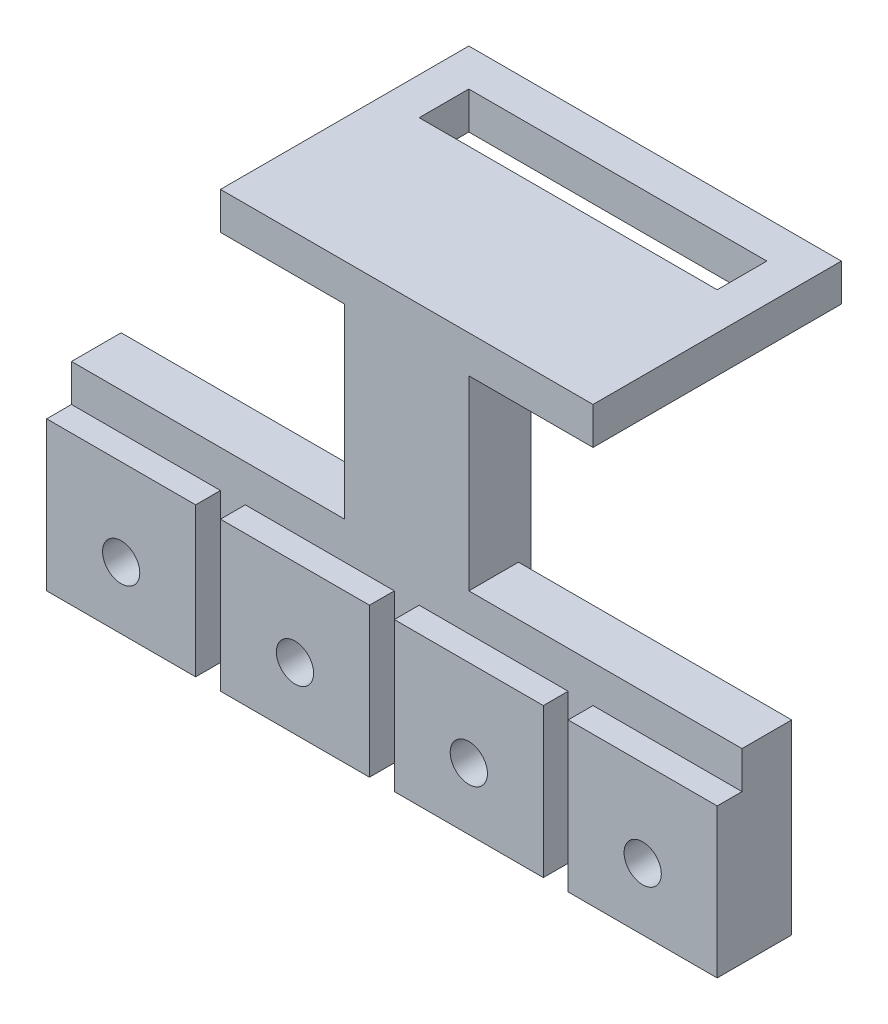
from build123d import *

# Parameters (mm, degrees)
SKETCH1_W                = 12
SKETCH1_H                = 12
BOSS_EXTRUDE1_DEPTH      = 2
SKETCH2_W                = 54
SKETCH2_H                = 15
BOSS_EXTRUDE2_DEPTH      = 4
SKETCH3_W                = 12
SKETCH3_H                = 12
BOSS_EXTRUDE3_DEPTH      = 2
SKETCH4_R                = 1.5
CUT_EXTRUDE1_DEPTH       = 9
SKETCH5_W                = 10
SKETCH5_H                = 5
BOSS_EXTRUDE4_DEPTH      = 15
BOSS_EXTRUDE4_DEPTH_BACK = 5
SKETCH6_W                = 30
SKETCH6_H                = 20
BOSS_EXTRUDE5_DEPTH      = 3
SKETCH7_W                = 24
SKETCH7_H                = 4
CUT_EXTRUDE2_DEPTH       = 3


with BuildPart() as part:
    # Sketch1 → Boss-Extrude1 (new body)
    with BuildSketch(Plane.XY):
        with Locations((1.668449198, -3.417112299)):
            Rectangle(SKETCH1_W, SKETCH1_H)
    extrude(amount=BOSS_EXTRUDE1_DEPTH)

    # Sketch2 → Boss-Extrude2 (add)
    with BuildSketch(Plane(origin=(0, 0, 0), x_dir=(-1, 0, 0), z_dir=(0, 0, -1))):
        with Locations((-22.668449198, -1.917112299)):
            Rectangle(SKETCH2_W, SKETCH2_H)
    extrude(amount=BOSS_EXTRUDE2_DEPTH)

    # Sketch3 → Boss-Extrude3 (add)
    with BuildSketch(Plane.XY):
        with Locations((15.668449198, -3.417112299)):
            Rectangle(SKETCH3_W, SKETCH3_H)
        with Locations((29.668449198, -3.417112299)):
            Rectangle(SKETCH3_W, SKETCH3_H)
        with Locations((43.668449198, -3.417112299)):
            Rectangle(SKETCH3_W, SKETCH3_H)
    extrude(amount=BOSS_EXTRUDE3_DEPTH)

    # Sketch4 → Cut-Extrude1 (cut)
    with BuildSketch(Plane.XY.offset(2)):
        with Locations((1.668449198, -4.417112299)):
            Circle(SKETCH4_R)
        with Locations((15.668449198, -4.417112299)):
            Circle(SKETCH4_R)
        with Locations((29.668449198, -4.417112299)):
            Circle(SKETCH4_R)
        with Locations((43.668449198, -4.417112299)):
            Circle(SKETCH4_R)
    extrude(amount=-CUT_EXTRUDE1_DEPTH, mode=Mode.SUBTRACT)

    # Sketch5 → Boss-Extrude4 (add, two sides)
    with BuildSketch(Plane(origin=(0, 5.582887701, 0), x_dir=(1, 0, 0), z_dir=(0, 1, 0))) as boss_extrude4_sk:
        with Locations((22.668449198, 2.5)):
            Rectangle(SKETCH5_W, SKETCH5_H)
    extrude(amount=BOSS_EXTRUDE4_DEPTH)
    extrude(boss_extrude4_sk.sketch, amount=-BOSS_EXTRUDE4_DEPTH_BACK)

    # Sketch6 → Boss-Extrude5 (add)
    with BuildSketch(Plane(origin=(0, 20.582887701, 0), x_dir=(1, 0, 0), z_dir=(0, 1, 0))):
        with Locations((22.668449198, 10)):
            Rectangle(SKETCH6_W, SKETCH6_H)
    extrude(amount=BOSS_EXTRUDE5_DEPTH)

    # Sketch7 → Cut-Extrude2 (cut)
    with BuildSketch(Plane(origin=(0, 23.582887701, 0), x_dir=(1, 0, 0), z_dir=(0, 1, 0))):
        with Locations((22.668449198, 15)):
            Rectangle(SKETCH7_W, SKETCH7_H)
    extrude(amount=-CUT_EXTRUDE2_DEPTH, mode=Mode.SUBTRACT)


solid = part.part
